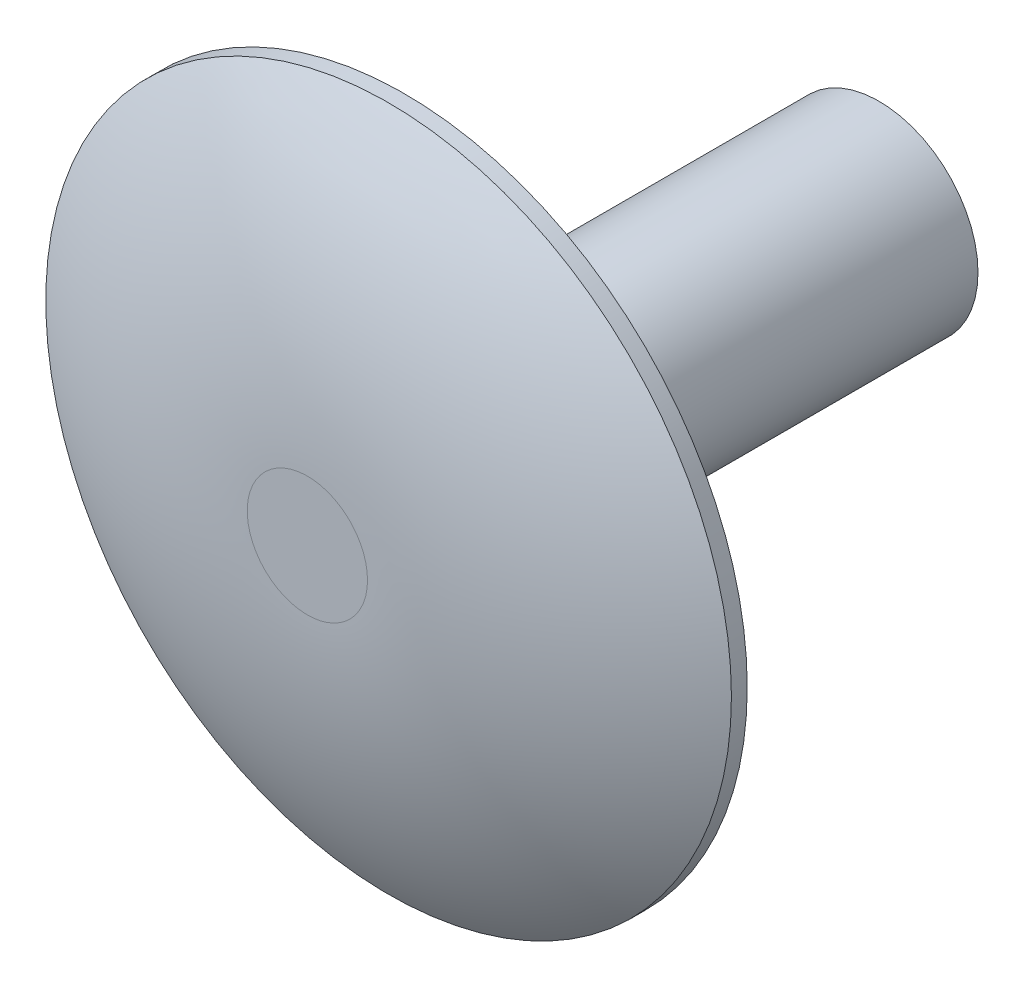
from build123d import *

# Parameters (mm, degrees)
SKETCH1_R           = 8.255
BOSS_EXTRUDE1_DEPTH = 2.3368
SKETCH2_R           = 2.38125
BOSS_EXTRUDE2_DEPTH = 11.43


with BuildPart() as part:
    # Sketch1 → Boss-Extrude1 (new body)
    with BuildSketch(Plane.XY):
        Circle(SKETCH1_R)
    extrude(amount=BOSS_EXTRUDE1_DEPTH)

    # Sketch2 → Boss-Extrude2 (add)
    with BuildSketch(Plane.XY):
        Circle(SKETCH2_R)
    extrude(amount=-BOSS_EXTRUDE2_DEPTH)

    # Sketch3 → Cut-Revolve1 (revolve, cut)
    with BuildSketch(Plane(origin=(0, 0, 0), x_dir=(1, 0, 0), z_dir=(0, 1, 0))):
        with BuildLine():
            ThreePointArc((1.4478, -2.3368), (4.989096566, -1.838155581), (8.255, -0.381))
            Line((8.255, -0.381), (8.255, -2.3368))
            Line((8.255, -2.3368), (1.4478, -2.3368))
        make_face()
    revolve(axis=Axis((0, 0, 2.3368), (0, 0, -1)), mode=Mode.SUBTRACT)


solid = part.part
